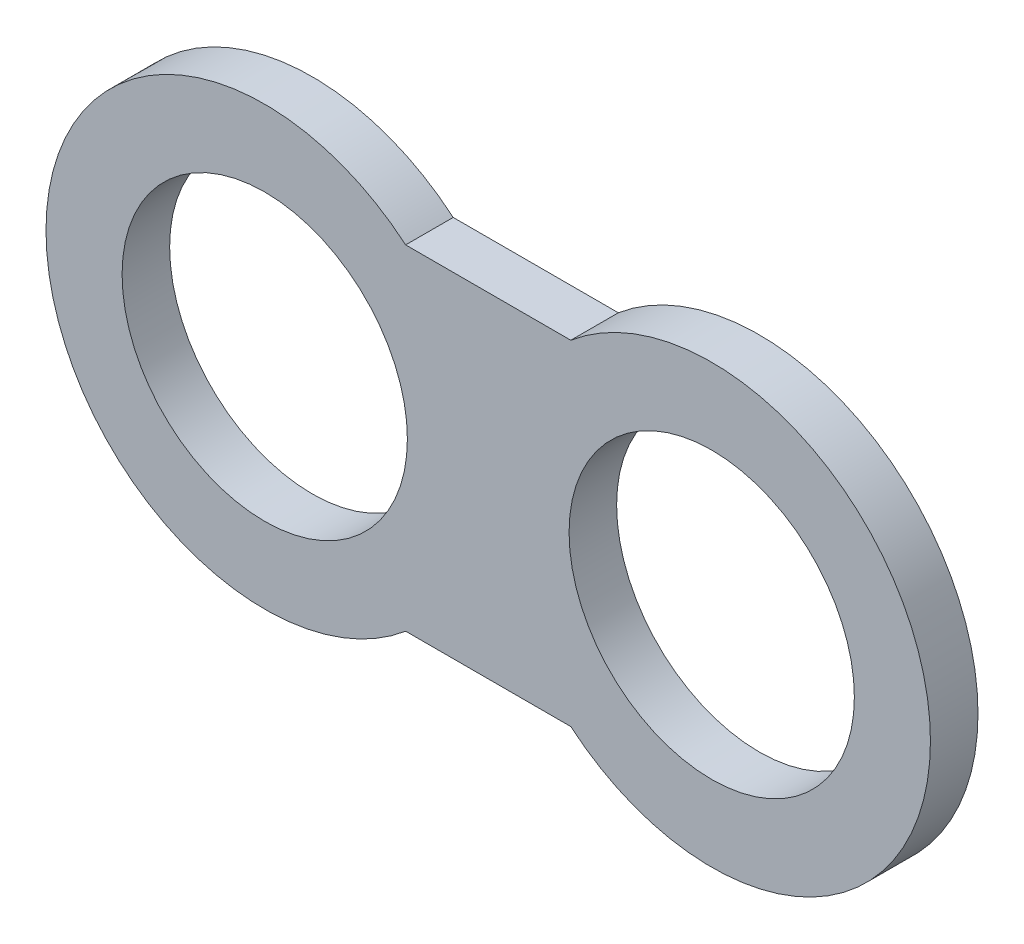
from build123d import *

# Parameters (mm, degrees)
BOSS_EXTRUDE1_DEPTH      = 25
BOSS_EXTRUDE1_DEPTH_BACK = 25
SKETCH4_R                = 150
BOSS_EXTRUDE2_START      = -25
SKETCH4_4_R              = 150
BOSS_EXTRUDE2_DEPTH      = 25


with BuildPart() as part:
    # Sketch4 → Boss-Extrude1 (new, two sides: drawn at the far end of the back side and taken through both)
    with BuildSketch(Plane.XY.offset(-BOSS_EXTRUDE1_DEPTH_BACK)):
        with BuildLine():
            Line((71.8245835, 175.909198012), (-101.8245835, 175.909198012))
            ThreePointArc((-101.8245835, 175.909198012), (-480, 0), (-101.8245835, -175.909198012))
            Line((-101.8245835, -175.909198012), (71.8245835, -175.909198012))
            ThreePointArc((71.8245835, -175.909198012), (450, 0), (71.8245835, 175.909198012))
        make_face()
        with Locations((220, 0)):
            Circle(SKETCH4_R, mode=Mode.SUBTRACT)
        with Locations((-250, 0)):
            Circle(SKETCH4_R, mode=Mode.SUBTRACT)
    extrude(amount=BOSS_EXTRUDE1_DEPTH + BOSS_EXTRUDE1_DEPTH_BACK)

    # Sketch4_4 → Boss-Extrude2 (add)
    with BuildSketch(Plane.XY.offset(BOSS_EXTRUDE2_START)):
        with BuildLine():
            ThreePointArc((-20, 0), (-41.45702386, 97.004263321), (-101.8245835, 175.909198012))
            ThreePointArc((-101.8245835, 175.909198012), (-480, 0), (-101.8245835, -175.909198012))
            ThreePointArc((-101.8245835, -175.909198012), (-41.45702386, -97.004263321), (-20, 0))
        make_face()
        with Locations((-250, 0)):
            Circle(SKETCH4_4_R, mode=Mode.SUBTRACT)
    extrude(amount=BOSS_EXTRUDE2_DEPTH)


solid = part.part
